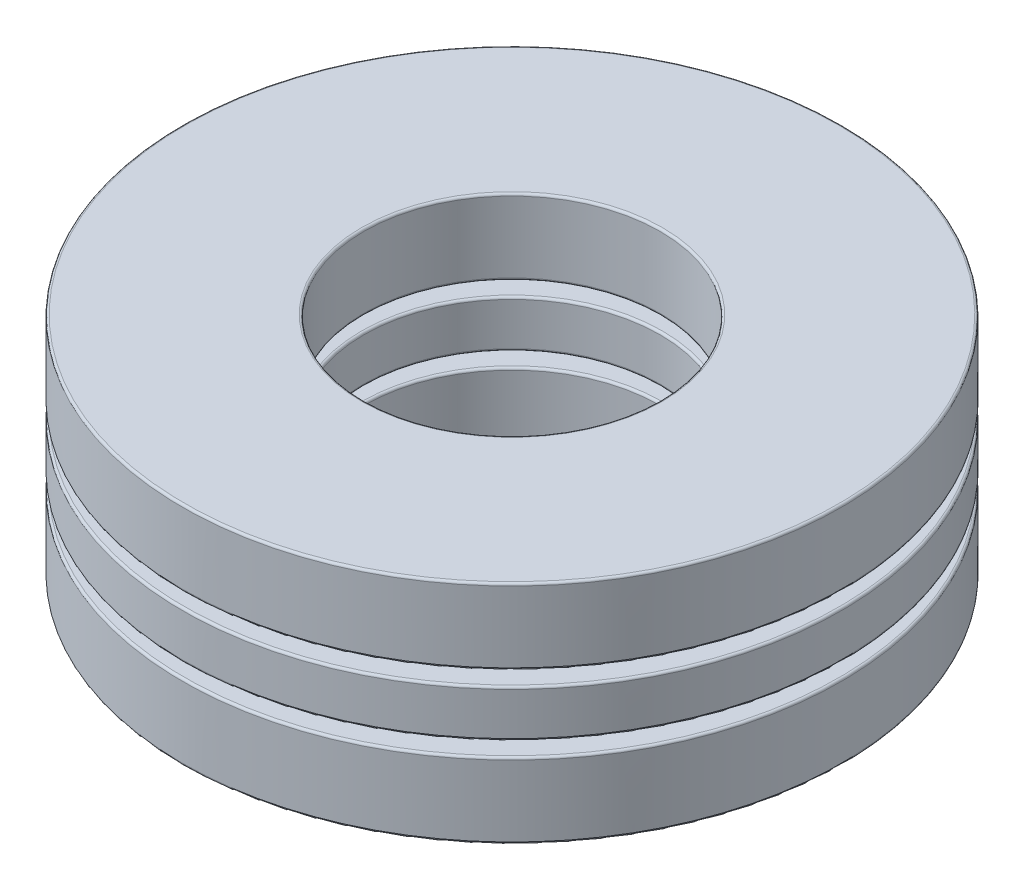
from build123d import *

# Parameters (mm, degrees)
SKETCH1_W         = 3.93065
SKETCH1_H         = 1.021291666
CIRPATTERN1_COUNT = 3
CIRPATTERN1_ANGLE = 240
CIRPATTERN2_COUNT = 3
SKETCH4_W         = 3.93065
SKETCH4_H         = 1.634066667
FILLET1_R         = 0.049022
FILLET2_R         = 0.049022
FILLET3_R         = 0.049022


with BuildPart() as part:
    # Sketch1 → Revolve1 (revolve)
    with BuildSketch(Plane(origin=(0, 0, 0), x_dir=(0, 0, -1), z_dir=(1, 0, 0))):
        with Locations((-5.178425, 0)):
            Rectangle(SKETCH1_W, SKETCH1_H)
    revolve(axis=Axis((0, -2.4511, 0), (0, 1, 0)))

    # Sketch3 → Cut-Revolve1 (revolve, cut)
    with BuildSketch(Plane(origin=(0, 0, 0), x_dir=(0, 0, -1), z_dir=(1, 0, 0))):
        with BuildLine():
            Line((-5.178425, 0.817033333), (-5.178425, -0.817033333))
            ThreePointArc((-5.178425, -0.817033333), (-5.995458333, 0), (-5.178425, 0.817033333))
        make_face()
    cut_revolve1 = revolve(axis=Axis((0, 0.817033333, 5.178425), (0, -1, 0)), mode=Mode.SUBTRACT)

    # CirPattern2: Cut-Revolve1 ×3 about axis
    cirpattern2_axis = Axis((0, 0, 0), (0, 1, 0))
    for i in range(1, CIRPATTERN2_COUNT):
        add(cut_revolve1.rotate(cirpattern2_axis, i * 360 / CIRPATTERN2_COUNT), mode=Mode.SUBTRACT)

    # Fillet2
    fillet2_edges = [part.edges().sort_by_distance(p)[0] for p in [
        (0, 0.510645833, -7.14375),
        (0, 0.510645833, -3.2131),
        (0, -0.510645833, -3.2131),
        (0, -0.510645833, -7.14375),
    ]]
    fillet(fillet2_edges, radius=FILLET2_R)


with BuildPart() as body_2:
    # Sketch2 → Revolve2 (revolve)
    with BuildSketch(Plane(origin=(0, 0, 0), x_dir=(0, 0, -1), z_dir=(1, 0, 0))):
        with BuildLine():
            Line((-5.178425, 0.817033333), (-5.178425, -0.817033333))
            ThreePointArc((-5.178425, -0.817033333), (-5.995458333, 0), (-5.178425, 0.817033333))
        make_face()
    revolve(axis=Axis((0, 0.817033333, 5.178425), (0, -1, 0)))


with BuildPart() as cirpattern1_1:
    # CirPattern1: pattern copy
    add(body_2.part.rotate(Axis((0, 2.4511, 0), (0, -1, 0)), 1 * CIRPATTERN1_ANGLE / (CIRPATTERN1_COUNT - 1)))


with BuildPart() as cirpattern1_2:
    # CirPattern1: pattern copy
    add(body_2.part.rotate(Axis((0, 2.4511, 0), (0, -1, 0)), 2 * CIRPATTERN1_ANGLE / (CIRPATTERN1_COUNT - 1)))


with BuildPart() as body_5:
    # Sketch4 → Revolve3 (revolve)
    with BuildSketch(Plane(origin=(0, 0, 0), x_dir=(0, 0, -1), z_dir=(1, 0, 0))):
        with Locations((-5.178425, 1.634066667)):
            Rectangle(SKETCH4_W, SKETCH4_H)
        with Locations((-5.178425, -1.634066667)):
            Rectangle(SKETCH4_W, SKETCH4_H)
    revolve(axis=Axis((0, -2.4511, 0), (0, 1, 0)))

    # Fillet1
    fillet1_edges = [body_5.edges().sort_by_distance(p)[0] for p in [
        (0, 0.817033333, -7.14375),
        (0, 0.817033333, -3.2131),
        (0, 2.4511, -3.2131),
        (0, 2.4511, -7.14375),
    ]]
    fillet(fillet1_edges, radius=FILLET1_R)

    # Fillet3
    fillet3_edges = [body_5.edges().sort_by_distance(p)[0] for p in [
        (0, -2.4511, -7.14375),
        (0, -2.4511, -3.2131),
        (0, -0.817033333, -3.2131),
        (0, -0.817033333, -7.14375),
    ]]
    fillet(fillet3_edges, radius=FILLET3_R)


solid = Compound([part.part, body_2.part, cirpattern1_1.part, cirpattern1_2.part, body_5.part])
